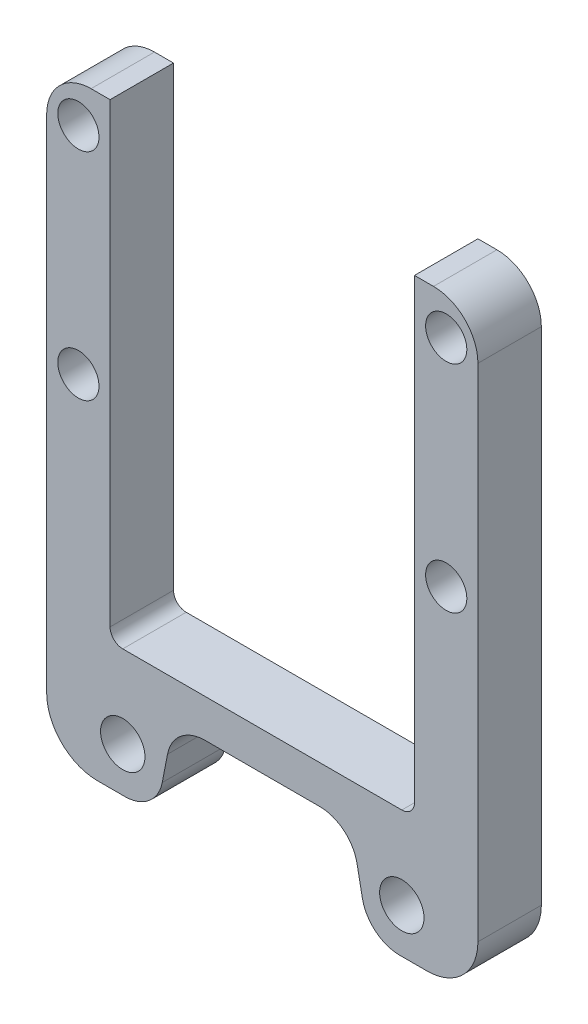
from build123d import *

# Parameters (mm, degrees)
ESQUISSE1_R        = 3.25
ESQUISSE1_R_2      = 3.5
BOSS_EXTRU_1_DEPTH = 10
CONG_1_R           = 6
CONG_2_R           = 8
CONG_3_R           = 7
CONG_4_R           = 2


with BuildPart() as part:
    # Esquisse1 → Boss.-Extru.1 (new body)
    with BuildSketch(Plane.XY):
        Polygon((24, 110), (24, 36), (0, 36), (0, 30), (14, 30), (16.721324328, 16), (34, 16), (34, 110), align=None)
        with Locations((29, 104)):
            Circle(ESQUISSE1_R, mode=Mode.SUBTRACT)
        with Locations((22, 23)):
            Circle(ESQUISSE1_R_2, mode=Mode.SUBTRACT)
        with Locations((29, 70)):
            Circle(ESQUISSE1_R, mode=Mode.SUBTRACT)
    boss_extru_1 = extrude(amount=BOSS_EXTRU_1_DEPTH)

    # Symétrie2: Boss.-Extru.1 across plane
    add(boss_extru_1.mirror(Plane(origin=(0, 36, 10), x_dir=(0, 0, 1), z_dir=(1, 0, 0))))

    # Congé1
    cong_1_edges = [part.edges().sort_by_distance(p)[0] for p in [
        (16.721324328, 16, 5),
        (14, 30, 5),
        (-14, 30, 5),
        (-16.721324328, 16, 5),
    ]]
    fillet(cong_1_edges, radius=CONG_1_R)

    # Congé2
    cong_2_edges = [part.edges().sort_by_distance(p)[0] for p in [
        (34, 16, 5),
        (-34, 16, 5),
    ]]
    fillet(cong_2_edges, radius=CONG_2_R)

    # Congé3
    cong_3_edges = [part.edges().sort_by_distance(p)[0] for p in [
        (34, 110, 5),
        (-34, 110, 5),
    ]]
    fillet(cong_3_edges, radius=CONG_3_R)

    # Congé4
    cong_4_edges = [part.edges().sort_by_distance(p)[0] for p in [
        (24, 36, 5),
        (-24, 36, 5),
    ]]
    fillet(cong_4_edges, radius=CONG_4_R)


solid = part.part
